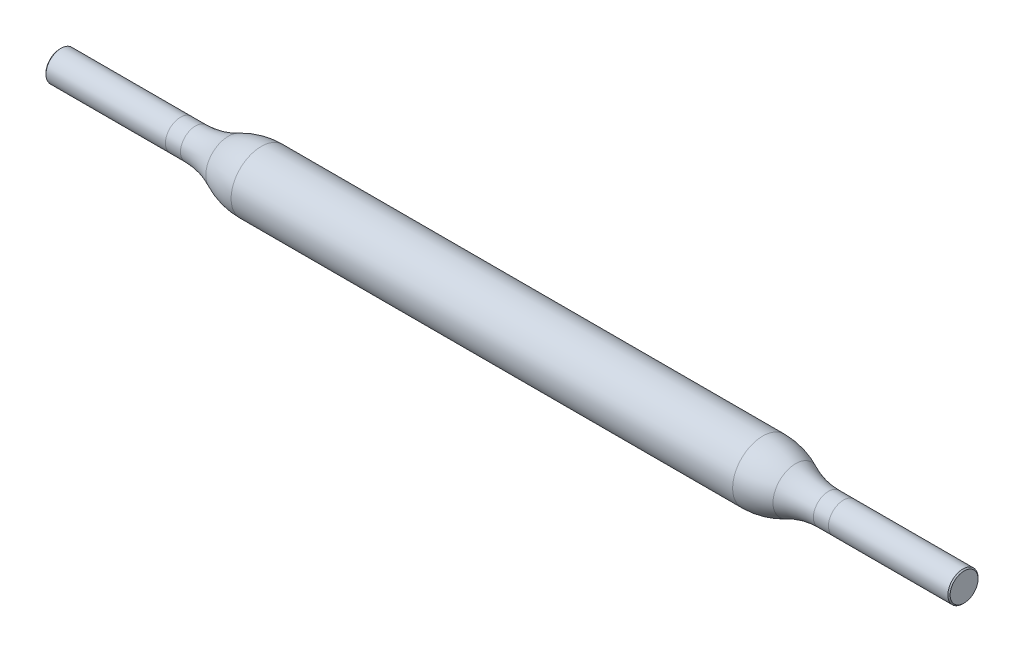
from build123d import *

# Parameters (mm, degrees)
CHAMFER1_SIZE = 0.075


with BuildPart() as part:
    # Sketch1 → Revolve1 (revolve)
    with BuildSketch(Plane.XY):
        with BuildLine():
            Line((-30, -3.052022418), (30, -3.052022418))
            Line((30, -3.052022418), (30, -2.052022418))
            Line((30, -2.052022418), (21, -2.052022418))
            ThreePointArc((21, -2.052022418), (19.881966011, -1.92541959), (18.820550528, -1.552022418))
            ThreePointArc((18.820550528, -1.552022418), (17.759135045, -1.178625246), (16.641101056, -1.052022418))
            Line((16.641101056, -1.052022418), (-16.641101056, -1.052022418))
            ThreePointArc((-16.641101056, -1.052022418), (-17.759135045, -1.178625246), (-18.820550528, -1.552022418))
            ThreePointArc((-18.820550528, -1.552022418), (-19.881966011, -1.92541959), (-21, -2.052022418))
            Line((-21, -2.052022418), (-30, -2.052022418))
            Line((-30, -2.052022418), (-30, -3.052022418))
        make_face()
    revolve(axis=Axis((-30, -3.052022418, 0), (1, 0, 0)))

    # Chamfer1
    chamfer1_edges = [part.edges().sort_by_distance(p)[0] for p in [
        (30, -4.052022418, 0),
        (-30, -4.052022418, 0),
    ]]
    chamfer(chamfer1_edges, length=CHAMFER1_SIZE)


solid = part.part
